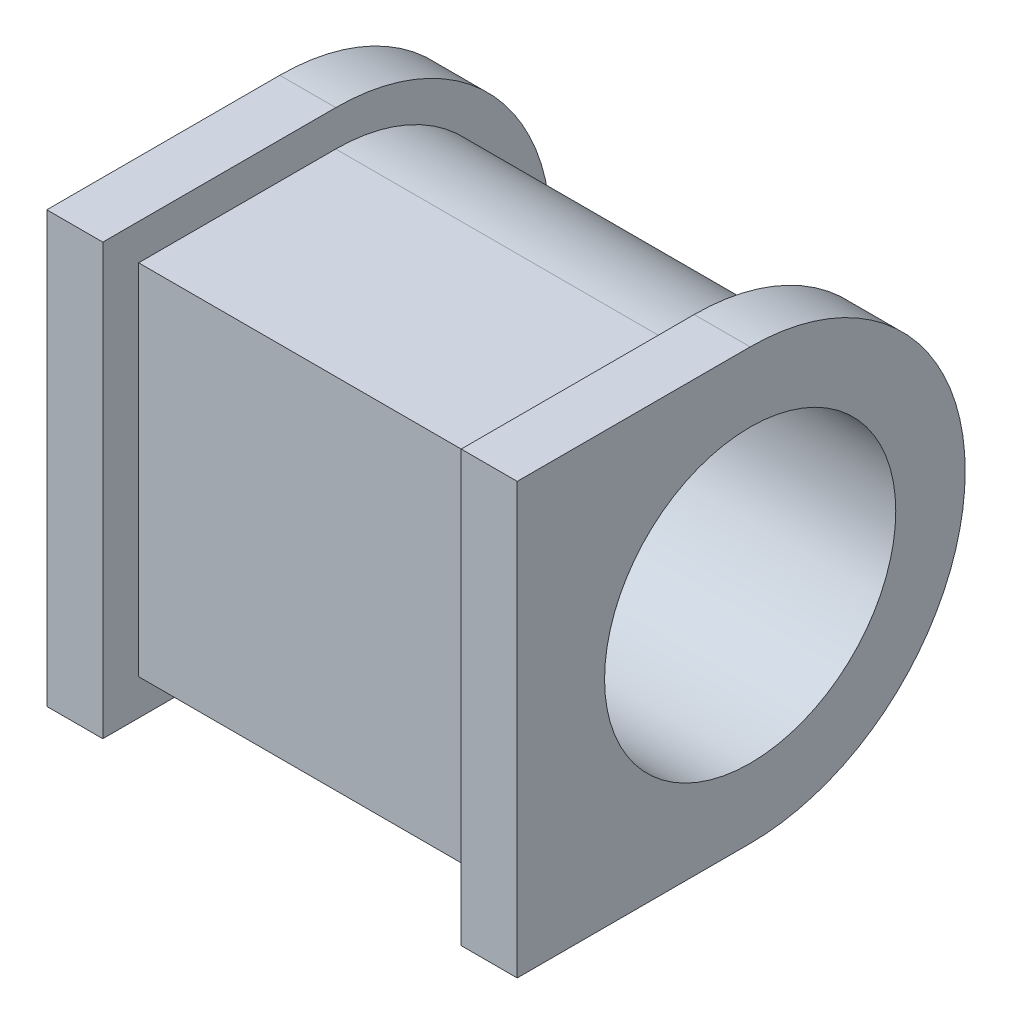
from build123d import *

# Parameters (mm, degrees)
SKETCH1_R           = 32.5
BOSS_EXTRUDE1_DEPTH = 12.5
SKETCH2_R           = 32.5
BOSS_EXTRUDE2_DEPTH = 80
SKETCH3_R           = 32.5
BOSS_EXTRUDE3_DEPTH = 12.5


with BuildPart() as part:
    # Sketch1 → Boss-Extrude1 (new body)
    with BuildSketch(Plane(origin=(0, 0, 0), x_dir=(0, 0, -1), z_dir=(1, 0, 0))):
        with BuildLine():
            Line((-52, 48), (-52, -48))
            Line((-52, -48), (0, -48))
            ThreePointArc((0, -48), (48, 0), (0, 48))
            Line((0, 48), (-52, 48))
        make_face()
        Circle(SKETCH1_R, mode=Mode.SUBTRACT)
    extrude(amount=BOSS_EXTRUDE1_DEPTH)

    # Sketch2 → Boss-Extrude2 (add)
    with BuildSketch(Plane(origin=(12.5, 0, 0), x_dir=(0, 0, -1), z_dir=(1, 0, 0))):
        with BuildLine():
            Line((0, 40), (-44, 40))
            Line((-44, 40), (-44, -40))
            Line((-44, -40), (0, -40))
            ThreePointArc((0, -40), (40, 0), (0, 40))
        make_face()
        Circle(SKETCH2_R, mode=Mode.SUBTRACT)
    extrude(amount=BOSS_EXTRUDE2_DEPTH)

    # Sketch3 → Boss-Extrude3 (add)
    with BuildSketch(Plane(origin=(92.5, 0, 0), x_dir=(0, 0, -1), z_dir=(1, 0, 0))):
        with BuildLine():
            Line((0, 48), (-52, 48))
            Line((-52, 48), (-52, -48))
            Line((-52, -48), (0, -48))
            ThreePointArc((0, -48), (48, 0), (0, 48))
        make_face()
        Circle(SKETCH3_R, mode=Mode.SUBTRACT)
    extrude(amount=BOSS_EXTRUDE3_DEPTH)


solid = part.part
